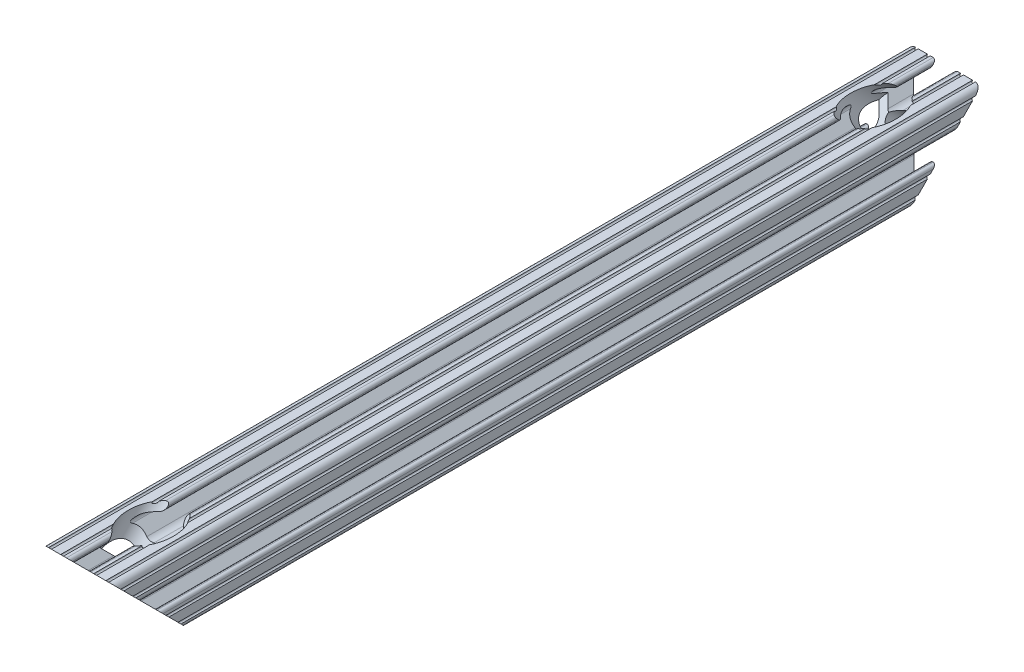
from build123d import *

# Parameters (mm, degrees)
SKETCH1_R               = 2.6035
BOSS_EXTRUDE1_DEPTH     = 152.4
CUT_EXTRUDE1_DEPTH      = 154.454683865
CUT_EXTRUDE1_DEPTH_BACK = 154.454683865
CUT_REVOLVE1_ANGLE      = 360


with BuildPart() as part:
    # Sketch1 → Boss-Extrude1 (new, symmetric)
    with BuildSketch(Plane.XY):
        with BuildLine():
            Line((-7.179650497, -8.645192506), (-3.952270251, -5.423690499))
            ThreePointArc((-3.952270251, -5.423690499), (-2.922936451, -4.736929036), (-1.709253557, -4.4958))
            Line((-1.709253557, -4.4958), (1.709253557, -4.4958))
            ThreePointArc((1.709253557, -4.4958), (2.922936451, -4.736929036), (3.952270251, -5.423690499))
            Line((3.952270251, -5.423690499), (7.179650497, -8.645192506))
            ThreePointArc((7.179650497, -8.645192506), (7.41473083, -9.822813117), (6.416408329, -10.4902))
            Line((6.416408329, -10.4902), (4.287512407, -10.4902))
            ThreePointArc((4.287512407, -10.4902), (3.54574862, -10.79744862), (3.2385, -11.539212407))
            Line((3.2385, -11.539212407), (3.2385, -11.650987593))
            ThreePointArc((3.2385, -11.650987593), (3.54574862, -12.39275138), (4.287512407, -12.7))
            Line((4.287512407, -12.7), (5.317126718, -12.7))
            ThreePointArc((5.317126718, -12.7), (5.825126718, -12.192), (6.333126718, -12.7))
            Line((6.333126718, -12.7), (9.550443118, -12.7))
            ThreePointArc((9.550443118, -12.7), (10.058366869, -12.192000006), (10.566443095, -12.699847501))
            ThreePointArc((10.566443095, -12.699847501), (12.082537762, -12.08250727), (12.699846982, -10.566399977))
            ThreePointArc((12.699846982, -10.566399977), (12.192000006, -10.058323491), (12.7, -9.5504))
            Line((12.7, -9.5504), (12.7, -6.3330836))
            ThreePointArc((12.7, -6.3330836), (12.192, -5.8250836), (12.7, -5.3170836))
            Line((12.7, -5.3170836), (12.7, -4.287469289))
            ThreePointArc((12.7, -4.287469289), (12.39275138, -3.545705502), (11.650987593, -3.238456882))
            Line((11.650987593, -3.238456882), (11.539212407, -3.238456882))
            ThreePointArc((11.539212407, -3.238456882), (10.79744862, -3.545705502), (10.4902, -4.287469289))
            Line((10.4902, -4.287469289), (10.4902, -6.402089023))
            ThreePointArc((10.4902, -6.402089023), (9.856505071, -7.351067942), (8.737131347, -7.129408934))
            Line((8.737131347, -7.129408934), (5.441005833, -3.840816462))
            ThreePointArc((5.441005833, -3.840816462), (4.750877967, -2.809883091), (4.5085, -1.593185507))
            Line((4.5085, -1.593185507), (4.5085, 1.593185507))
            ThreePointArc((4.5085, 1.593185507), (4.750877967, 2.809883091), (5.441005833, 3.840816462))
            Line((5.441005833, 3.840816462), (8.737131347, 7.129408934))
            ThreePointArc((8.737131347, 7.129408934), (9.856505071, 7.351067942), (10.4902, 6.402089023))
            Line((10.4902, 6.402089023), (10.4902, 4.287469289))
            ThreePointArc((10.4902, 4.287469289), (10.79744862, 3.545705502), (11.539212407, 3.238456882))
            Line((11.539212407, 3.238456882), (11.650987593, 3.238456882))
            ThreePointArc((11.650987593, 3.238456882), (12.39275138, 3.545705502), (12.7, 4.287469289))
            Line((12.7, 4.287469289), (12.7, 5.3170836))
            ThreePointArc((12.7, 5.3170836), (12.192, 5.8250836), (12.7, 6.3330836))
            Line((12.7, 6.3330836), (12.7, 9.5504))
            ThreePointArc((12.7, 9.5504), (12.192000006, 10.058323491), (12.699846982, 10.566399977))
            ThreePointArc((12.699846982, 10.566399977), (12.082537762, 12.08250727), (10.566443095, 12.699847501))
            ThreePointArc((10.566443095, 12.699847501), (10.058366869, 12.192000006), (9.550443118, 12.7))
            Line((9.550443118, 12.7), (6.333126718, 12.7))
            ThreePointArc((6.333126718, 12.7), (5.825126718, 12.192), (5.317126718, 12.7))
            Line((5.317126718, 12.7), (4.287512407, 12.7))
            ThreePointArc((4.287512407, 12.7), (3.54574862, 12.39275138), (3.2385, 11.650987593))
            Line((3.2385, 11.650987593), (3.2385, 11.539212407))
            ThreePointArc((3.2385, 11.539212407), (3.54574862, 10.79744862), (4.287512407, 10.4902))
            Line((4.287512407, 10.4902), (6.476788598, 10.4902))
            ThreePointArc((6.476788598, 10.4902), (7.432222385, 9.85140422), (7.207036008, 8.724370562))
            Line((7.207036008, 8.724370562), (3.898272566, 5.423169045))
            ThreePointArc((3.898272566, 5.423169045), (2.869120213, 4.736787962), (1.655778399, 4.4958))
            Line((1.655778399, 4.4958), (-1.655778399, 4.4958))
            ThreePointArc((-1.655778399, 4.4958), (-2.869120213, 4.736787962), (-3.898272566, 5.423169045))
            Line((-3.898272566, 5.423169045), (-7.207036008, 8.724370562))
            ThreePointArc((-7.207036008, 8.724370562), (-7.432222385, 9.85140422), (-6.476788598, 10.4902))
            Line((-6.476788598, 10.4902), (-4.287512407, 10.4902))
            ThreePointArc((-4.287512407, 10.4902), (-3.54574862, 10.79744862), (-3.2385, 11.539212407))
            Line((-3.2385, 11.539212407), (-3.2385, 11.650987593))
            ThreePointArc((-3.2385, 11.650987593), (-3.54574862, 12.39275138), (-4.287512407, 12.7))
            Line((-4.287512407, 12.7), (-5.317126718, 12.7))
            ThreePointArc((-5.317126718, 12.7), (-5.825126718, 12.192), (-6.333126718, 12.7))
            Line((-6.333126718, 12.7), (-9.550443118, 12.7))
            ThreePointArc((-9.550443118, 12.7), (-10.058366869, 12.192000006), (-10.566443095, 12.699847501))
            ThreePointArc((-10.566443095, 12.699847501), (-12.082537762, 12.08250727), (-12.699846982, 10.566399977))
            ThreePointArc((-12.699846982, 10.566399977), (-12.192000006, 10.058323491), (-12.7, 9.5504))
            Line((-12.7, 9.5504), (-12.7, 6.3330836))
            ThreePointArc((-12.7, 6.3330836), (-12.192, 5.8250836), (-12.7, 5.3170836))
            Line((-12.7, 5.3170836), (-12.7, 4.287469289))
            ThreePointArc((-12.7, 4.287469289), (-12.39275138, 3.545705502), (-11.650987593, 3.238456882))
            Line((-11.650987593, 3.238456882), (-11.539212407, 3.238456882))
            ThreePointArc((-11.539212407, 3.238456882), (-10.79744862, 3.545705502), (-10.4902, 4.287469289))
            Line((-10.4902, 4.287469289), (-10.4902, 6.402089023))
            ThreePointArc((-10.4902, 6.402089023), (-9.856505071, 7.351067942), (-8.737131347, 7.129408934))
            Line((-8.737131347, 7.129408934), (-5.441005833, 3.840816462))
            ThreePointArc((-5.441005833, 3.840816462), (-4.750877967, 2.809883091), (-4.5085, 1.593185507))
            Line((-4.5085, 1.593185507), (-4.5085, -1.593185507))
            ThreePointArc((-4.5085, -1.593185507), (-4.750877967, -2.809883091), (-5.441005833, -3.840816462))
            Line((-5.441005833, -3.840816462), (-8.737131347, -7.129408934))
            ThreePointArc((-8.737131347, -7.129408934), (-9.856505071, -7.351067942), (-10.4902, -6.402089023))
            Line((-10.4902, -6.402089023), (-10.4902, -4.287469289))
            ThreePointArc((-10.4902, -4.287469289), (-10.79744862, -3.545705502), (-11.539212407, -3.238456882))
            Line((-11.539212407, -3.238456882), (-11.650987593, -3.238456882))
            ThreePointArc((-11.650987593, -3.238456882), (-12.39275138, -3.545705502), (-12.7, -4.287469289))
            Line((-12.7, -4.287469289), (-12.7, -5.3170836))
            ThreePointArc((-12.7, -5.3170836), (-12.192, -5.8250836), (-12.7, -6.3330836))
            Line((-12.7, -6.3330836), (-12.7, -9.5504))
            ThreePointArc((-12.7, -9.5504), (-12.192000006, -10.058323491), (-12.699846982, -10.566399977))
            ThreePointArc((-12.699846982, -10.566399977), (-12.082537762, -12.08250727), (-10.566443095, -12.699847501))
            ThreePointArc((-10.566443095, -12.699847501), (-10.058366869, -12.192000006), (-9.550443118, -12.7))
            Line((-9.550443118, -12.7), (-6.333126718, -12.7))
            ThreePointArc((-6.333126718, -12.7), (-5.825126718, -12.192), (-5.317126718, -12.7))
            Line((-5.317126718, -12.7), (-4.287512407, -12.7))
            ThreePointArc((-4.287512407, -12.7), (-3.54574862, -12.39275138), (-3.2385, -11.650987593))
            Line((-3.2385, -11.650987593), (-3.2385, -11.539212407))
            ThreePointArc((-3.2385, -11.539212407), (-3.54574862, -10.79744862), (-4.287512407, -10.4902))
            Line((-4.287512407, -10.4902), (-6.416408329, -10.4902))
            ThreePointArc((-6.416408329, -10.4902), (-7.41473083, -9.822813117), (-7.179650497, -8.645192506))
        make_face()
        with Locations(Location((0, 0, 0), (0, 0, 180))):
            Circle(SKETCH1_R, mode=Mode.SUBTRACT)
    extrude(amount=BOSS_EXTRUDE1_DEPTH, both=True)

    # Sketch2 → Cut-Extrude1 (cut, two sides)
    with BuildSketch(Plane(origin=(0, 0, 0), x_dir=(0, 0, -1), z_dir=(1, 0, 0))) as cut_extrude1_sk:
        Polygon((-152.4, 12.699847501), (-152.4, -12.7), (-127.000152499, -12.7), align=None)
        Polygon((127.000152499, -12.7), (152.4, 12.699847501), (152.4, -12.7), align=None)
    extrude(amount=CUT_EXTRUDE1_DEPTH, mode=Mode.SUBTRACT)
    extrude(cut_extrude1_sk.sketch, amount=-CUT_EXTRUDE1_DEPTH_BACK, mode=Mode.SUBTRACT)

    # Sketch3 → Cut-Revolve1 (revolve, symmetric, cut)
    with BuildSketch(Plane(origin=(0, 0, 0), x_dir=(0, 0, -1), z_dir=(1, 0, 0))) as cut_revolve1_sk:
        Polygon((-121.387644922, 18.312507577), (-139.700152499, 0), (-142.008078322, 2.307925823), (-137.517950261, 6.798053884), (-140.822684514, 10.102788136), (-127.000304998, 23.925167653), align=None)
    cut_revolve1 = revolve(axis=Axis((0, 0, 139.700152499), (0, -0.7071067811865485, 0.7071067811865467)), revolution_arc=CUT_REVOLVE1_ANGLE / 2, mode=Mode.SUBTRACT)
    cut_revolve1 = cut_revolve1 + revolve(cut_revolve1_sk.sketch, axis=Axis((0, 0, 139.700152499), (0, 0.7071067811865485, -0.7071067811865467)), revolution_arc=CUT_REVOLVE1_ANGLE / 2, mode=Mode.SUBTRACT)

    # Mirror1: Cut-Revolve1 across plane
    add(cut_revolve1.mirror(Plane.XY), mode=Mode.SUBTRACT)


solid = part.part
